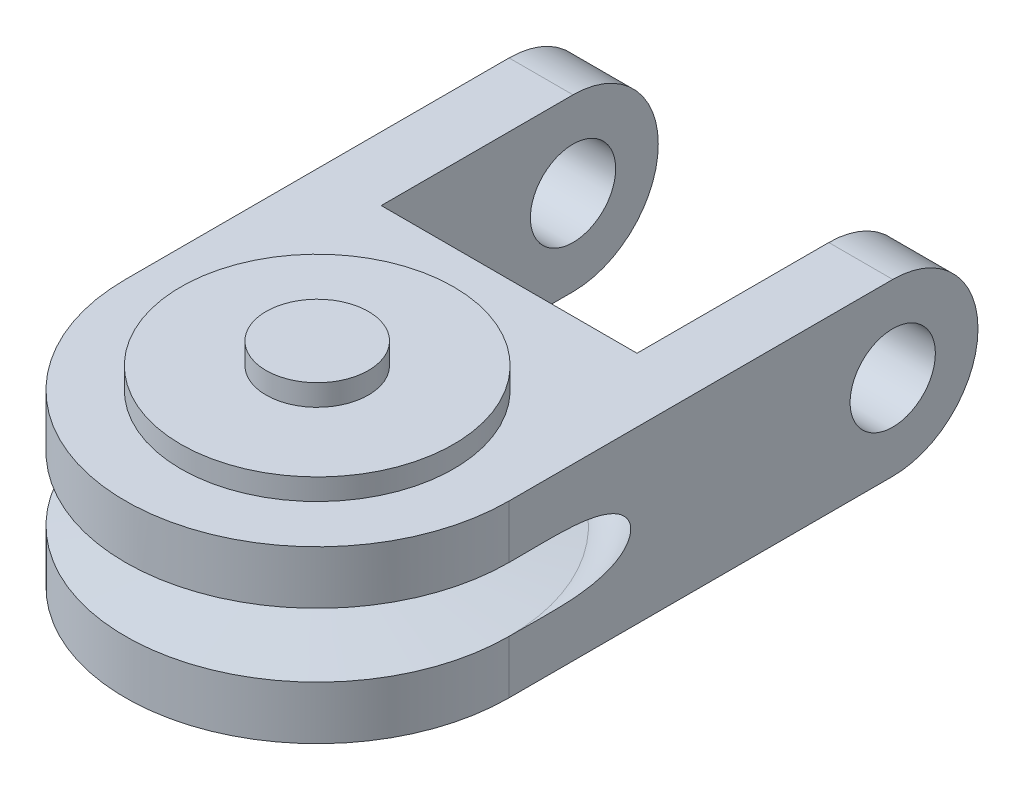
from build123d import *
from build123d.topology import SkipClean

# Parameters (mm, degrees)
SKETCH4_R            = 6.4
SKETCH4_R_2          = 2
BOSS_EXTRUDE3_DEPTH  = 1
BOSS_EXTRUDE6_START  = -3
SKETCH5_R            = 2
BOSS_EXTRUDE6_DEPTH  = 3.0001
BOSS_EXTRUDE22_REACH = 27.788
SKETCH9_R            = 6.419042014
BOSS_EXTRUDE9_DEPTH  = 1
BOSS_EXTRUDE23_REACH = 27.788


with BuildPart() as part:
    # Sketch3 → Revolve1 (revolve)
    with BuildSketch(Plane(origin=(0, 0, 0), x_dir=(0, 0, -1), z_dir=(1, 0, 0))):
        Polygon((-9, -1.5), (-4, -1), (-4, 1), (-9, 1.5), (-9, 4), (-2.4, 4), (-2.4, 6), (0, 6), (0, -6), (-2.4, -6), (-2.4, -4), (-9, -4), align=None)
    revolve(axis=Axis((0, 6, 0), (0, -1, 0)))



with BuildPart() as body_2:
    # Sketch4 → Boss-Extrude3 (new body)
    with BuildSketch(Plane(origin=(0, 4, 0), x_dir=(1, 0, 0), z_dir=(0, 1, 0))):
        with Locations(Location((0, 0, 0), (0, 0, 270))):
            Circle(SKETCH4_R)
        with Locations(Location((0, 0, 0), (0, 0, 270))):
            Circle(SKETCH4_R_2, mode=Mode.SUBTRACT)
    extrude(amount=BOSS_EXTRUDE3_DEPTH)


with BuildPart() as part_1:
    add(part.part)

    add(body_2.part)  # Boss-Extrude6 merges body 2
    # Sketch5 → Boss-Extrude6 (add)
    with BuildSketch(Plane(origin=(-6, 0, 3.854187267), x_dir=(0, 0, -1), z_dir=(1, 0, 0)).offset(BOSS_EXTRUDE6_START)):
        with BuildLine():
            ThreePointArc((21.854187267, -4), (25.854187267, 0), (21.854187267, 4))
            Line((21.854187267, 4), (3.854187267, 4))
            Line((3.854187267, 4), (3.854187267, -4))
            Line((3.854187267, -4), (21.854187267, -4))
        make_face()
        with Locations((21.854187267, 0)):
            Circle(SKETCH5_R, mode=Mode.SUBTRACT)
    boss_extrude6 = extrude(amount=BOSS_EXTRUDE6_DEPTH)

    # Mirror1: Boss-Extrude6 across plane
    add(boss_extrude6.mirror(Plane(origin=(0, 0, 0), x_dir=(0, 0, 1), z_dir=(1, 0, 0))))

    # Boss-Extrude22: up to this cone (the profile starts inside it)
    with SkipClean():  # the faces are left unmerged after this step: merging them gives an invalid solid
        boss_extrude22_end = Plane(origin=(0, -4, 0), z_dir=(0, -1, 0)).offset(-3.399999) * Cone(1e-05, 656.88, 65.687999, align=(Align.CENTER, Align.CENTER, Align.MIN), mode=Mode.PRIVATE)
        # Sketch18 → Boss-Extrude22 (add, up to the surface)
        with BuildSketch(Plane.XZ.offset(4), mode=Mode.PRIVATE) as boss_extrude22_sk1:
            Polygon((-6, -9.001972309), (5.9999, -9.001972309), (5.9999, -5.707140078), (-6, -5.888545051), align=None)
        boss_extrude22_tool1 = extrude(boss_extrude22_sk1.sketch, amount=-BOSS_EXTRUDE22_REACH, mode=Mode.PRIVATE) & boss_extrude22_end
        add(boss_extrude22_tool1.solids().sort_by_distance((0.056566, -4, -7.39948))[0])

    # Sketch9 → Boss-Extrude9 (add)
    with SkipClean():  # the faces are left unmerged after this step: merging them gives an invalid solid
        with BuildSketch(Plane(origin=(0, -4, 0), x_dir=(-1, 0, 0), z_dir=(0, -1, 0))):
            with Locations(Location((0, 0, 0), (0, 0, 90))):
                Circle(SKETCH9_R)
        extrude(amount=BOSS_EXTRUDE9_DEPTH)

    # Sketch11 → Cut-Revolve3 (revolve, cut)
    with SkipClean():  # the faces are left unmerged after this step: merging them gives an invalid solid
        with BuildSketch(Plane(origin=(0, 0, 0), x_dir=(0, 0, -1), z_dir=(1, 0, 0)), mode=Mode.PRIVATE) as cut_revolve3_sk:
            with BuildLine():
                ThreePointArc((-9, -1.5), (-10.657481343, 0), (-9, 1.5))
                Line((-9, 1.5), (-4, 1))
                Line((-4, 1), (-4, -1))
                Line((-4, -1), (-9, -1.5))
            make_face()
        revolve(cut_revolve3_sk.sketch.rotate(Axis((0, 6, 0), (0, -1, 0)), 180), axis=Axis((0, 6, 0), (0, -1, 0)), mode=Mode.SUBTRACT)

    # Boss-Extrude23: up to this cone (the profile starts inside it)
    boss_extrude23_end = Plane(origin=(0, 4, 0), z_dir=(0, 1, 0)).offset(-3.399999) * Cone(1e-05, 656.88, 65.687999, align=(Align.CENTER, Align.CENTER, Align.MIN), mode=Mode.PRIVATE)
    # Sketch22 → Boss-Extrude23 (add, up to the surface)
    with BuildSketch(Plane(origin=(0, 4, 0), x_dir=(1, 0, 0), z_dir=(0, 1, 0)), mode=Mode.PRIVATE) as boss_extrude23_sk1:
        Polygon((5.9999, 9.001972309), (-6, 9.001972309), (-6, 5.888545051), (5.9999, 5.707140078), align=None)
    boss_extrude23_tool1 = extrude(boss_extrude23_sk1.sketch, amount=-BOSS_EXTRUDE23_REACH, mode=Mode.PRIVATE) & boss_extrude23_end
    add(boss_extrude23_tool1.solids().sort_by_distance((0.056566, 4, -7.39948))[0])


solid = part_1.part
